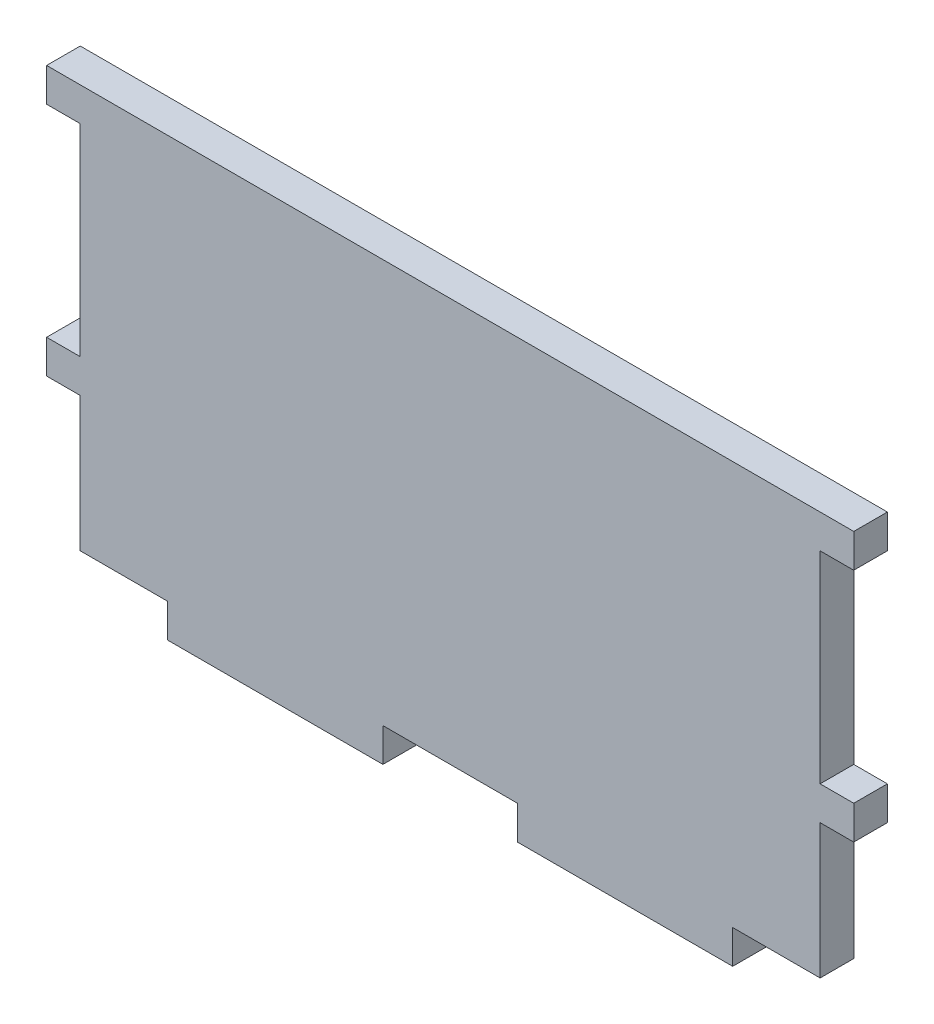
from build123d import *

# Parameters (mm, degrees)
SKETCH1_W           = 69.85
SKETCH1_H           = 38.1
BOSS_EXTRUDE1_DEPTH = 3.175
SKETCH2_W           = 3.175
SKETCH2_H           = 3.175
BOSS_EXTRUDE2_DEPTH = 3.175
SKETCH3_W           = 20.32
SKETCH3_H           = 3.175
BOSS_EXTRUDE3_DEPTH = 3.175


with BuildPart() as part:
    # Sketch1 → Boss-Extrude1 (new body)
    with BuildSketch(Plane.XY):
        Rectangle(SKETCH1_W, SKETCH1_H)
    extrude(amount=BOSS_EXTRUDE1_DEPTH)

    # Sketch2 → Boss-Extrude2 (add)
    with BuildSketch(Plane(origin=(0, 0, 0), x_dir=(-1, 0, 0), z_dir=(0, 0, -1))):
        with Locations((-36.5125, 17.4625)):
            Rectangle(SKETCH2_W, SKETCH2_H)
        with Locations((-36.5125, -4.7625)):
            Rectangle(SKETCH2_W, SKETCH2_H)
        with Locations((36.5125, 17.4625)):
            Rectangle(SKETCH2_W, SKETCH2_H)
        with Locations((36.5125, -4.7625)):
            Rectangle(SKETCH2_W, SKETCH2_H)
    extrude(amount=-BOSS_EXTRUDE2_DEPTH)

    # Sketch3 → Boss-Extrude3 (add)
    with BuildSketch(Plane.XZ.offset(19.05)):
        with Locations((-16.51, 1.5875)):
            Rectangle(SKETCH3_W, SKETCH3_H)
        with Locations((16.51, 1.5875)):
            Rectangle(SKETCH3_W, SKETCH3_H)
    extrude(amount=BOSS_EXTRUDE3_DEPTH)


solid = part.part
